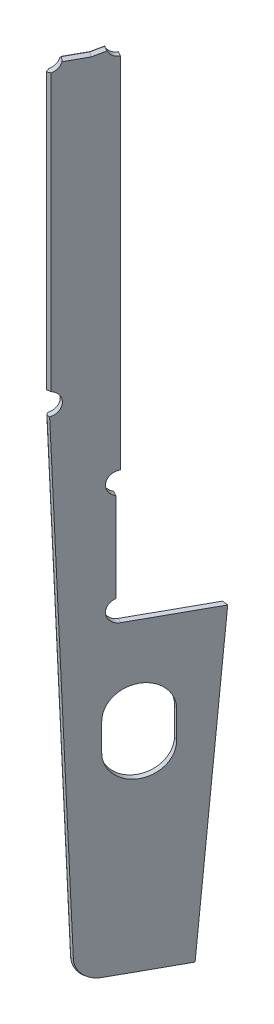
from build123d import *
from OCP.BRepFilletAPI import BRepFilletAPI_MakeChamfer

# Parameters (mm, degrees)
EXTRUDE1_DEPTH     = 40
CUT_EXTRUDE2_DEPTH = 17548.470493518
FASE1_SIZE         = 19
FASE1_SIZE2        = 8.859845505
FASE2_SIZE         = 19
FASE3_SIZE         = 38
FASE3_SIZE2        = 16.918690042


with BuildPart() as part:
    # Sketch2 → Extrude1 (new body)
    with BuildSketch(Plane(origin=(0, 0, 0), x_dir=(0.48480962024633806, 0, -0.8746197071393953), z_dir=(0.8746197071393953, 0, 0.48480962024633806))):
        with BuildLine():
            Line((1075, 14644.006579232), (1075, 13995.993420768))
            ThreePointArc((1075, 13995.993420768), (1021.007995147, 13907.340490954), (1100, 13840))
            Line((1100, 13840), (1672.487358177, 13840))
            Line((1672.487358177, 13840), (1497.747490562, 11620))
            Line((1497.747490562, 11620), (999.665169331, 11620))
            ThreePointArc((999.665169331, 11620), (888.632351027, 11664.79504592), (839.7690046, 11774.09855115))
            Line((839.7690046, 11774.09855115), (712.953240896, 15207.054528782))
            ThreePointArc((712.953240896, 15207.054528782), (789.986366643, 15288.476872132), (710, 15367))
            Line((710, 15367), (710, 17366))
            ThreePointArc((710, 17366), (766.568542495, 17389.431457505), (790, 17446))
            Line((790, 17446), (941.828079556, 17446))
            Line((941.828079556, 17446), (1021.626625497, 17465.949636485))
            ThreePointArc((1021.626625497, 17465.949636485), (1049.423469283, 17420.016013837), (1100, 17402))
            Line((1100, 17402), (1100, 14800))
            ThreePointArc((1100, 14800), (1021.007995147, 14732.659509046), (1075, 14644.006579232))
        make_face()
    extrude(amount=-EXTRUDE1_DEPTH)

    # Sketch4 → Cut-Extrude2 (cut, through all)
    with BuildSketch(Plane(origin=(0, 0, 0), x_dir=(0.48480962024633806, 0, -0.8746197071393953), z_dir=(0.8746197071393953, 0, 0.48480962024633806))):
        with BuildLine():
            Line((1400, 13240), (1400, 13040))
            ThreePointArc((1400, 13040), (1200, 12840), (1000, 13040))
            Line((1000, 13040), (1000, 13240))
            ThreePointArc((1000, 13240), (1200, 13440), (1400, 13240))
        make_face()
    extrude(amount=-CUT_EXTRUDE2_DEPTH, mode=Mode.SUBTRACT)

    # Fase1: one chamfer whose edges measure the first distance from different faces: ONE call of the kernel's chamfer builder (chamfer() names one face for all edges)
    fase1_edges_1 = [part.edges().sort_by_distance(p)[0] for p in [
        (605.384841621, 11620, -1092.143164601),
        (570.400053335, 11620, -1111.535549411),
    ]]
    fase1_side_1 = [part.faces().sort_by_distance(p)[0] for p in [
        (587.892447478, 11620, -1101.839357006),
    ]]
    fase1_edges_2 = [part.edges().sort_by_distance(p)[0] for p in [
        (430.81751264, 11664.79504592, -777.21536661),
        (395.832724354, 11664.79504592, -796.60775142),
    ]]
    fase1_side_2 = [part.faces().sort_by_distance(p)[0] for p in [
        (413.325118497, 11664.79504592, -786.911559015),
    ]]
    fase1_edges_3 = [part.edges().sort_by_distance(p)[0] for p in [
        (376.387341094, 13490.576539966, -679.020737812),
        (341.402552808, 13490.576539966, -698.413122622),
    ]]
    fase1_side_3 = [part.faces().sort_by_distance(p)[0] for p in [
        (358.894946951, 13490.576539966, -688.716930217),
    ]]
    fase1 = BRepFilletAPI_MakeChamfer(part.part.solid().wrapped)
    for e in fase1_edges_1:
        fase1.Add(FASE1_SIZE, FASE1_SIZE2, e.wrapped, fase1_side_1[0].wrapped)  # the first distance lies on this face
    for e in fase1_edges_2:
        fase1.Add(FASE1_SIZE, FASE1_SIZE2, e.wrapped, fase1_side_2[0].wrapped)  # the first distance lies on this face
    for e in fase1_edges_3:
        fase1.Add(FASE1_SIZE, FASE1_SIZE2, e.wrapped, fase1_side_3[0].wrapped)  # the first distance lies on this face
    add(Compound.cast(fase1.Shape()), mode=Mode.REPLACE)

    # Fase2
    fase2_edges = [part.edges().sort_by_distance(p)[0] for p in [
        (440.966076678, 17455.974818243, -878.030474367),
        (384.818668505, 17446, -776.737868688),
        (344.214830375, 16366.5, -620.979992069),
        (419.803456791, 17446, -757.345483879),
        (475.950864964, 17455.974818243, -858.638089557),
        (309.230042089, 16366.5, -640.372376879),
    ]]
    chamfer(fase2_edges, length=FASE2_SIZE)

    # Fase3
    fase3_edges = [part.edges().sort_by_distance(p)[0] for p in [
        (733.664434857, 12734.429922752, -1406.072290412),
    ]]
    fase3_side = [part.faces().sort_by_distance(p)[0] for p in [
        (751.068018003, 12732.102600682, -1396.215878727),
    ]]
    chamfer(fase3_edges, length=FASE3_SIZE, length2=FASE3_SIZE2, reference=fase3_side[0])


solid = part.part
